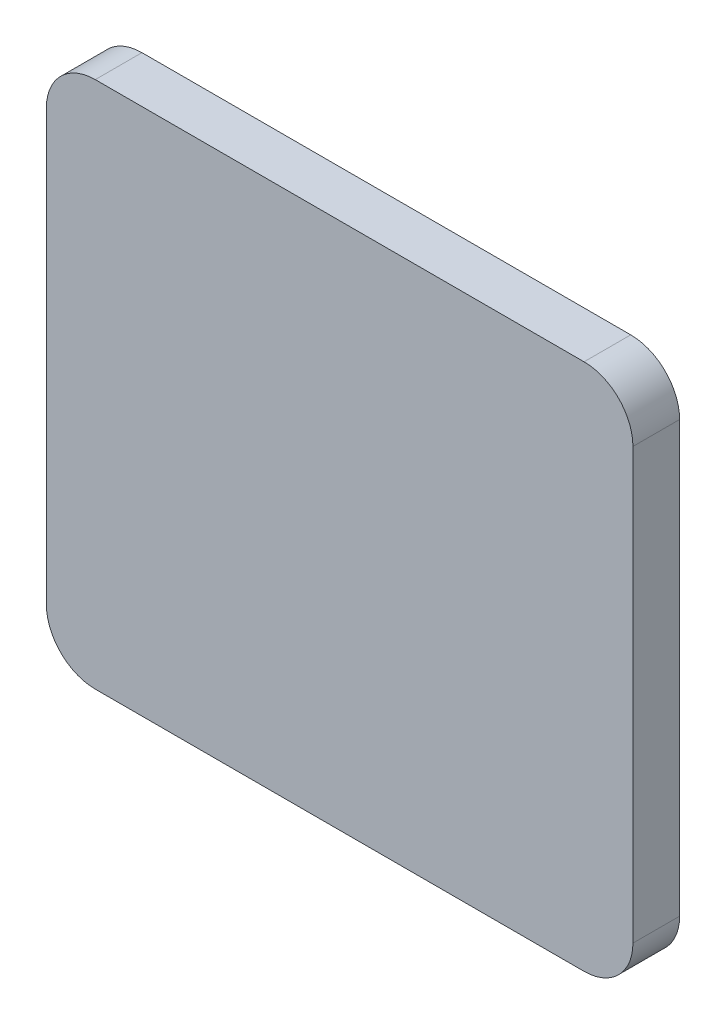
from build123d import *

# Parameters (mm, degrees)
BOSS_EXTRUDE1_DEPTH = 4.7752


with BuildPart() as part:
    # Sketch1 → Boss-Extrude1 (new body)
    with BuildSketch(Plane.XY):
        with BuildLine():
            Line((0, 5), (0, 49))
            ThreePointArc((0, 49), (1.464466094, 52.535533906), (5, 54))
            Line((5, 54), (55, 54))
            ThreePointArc((55, 54), (58.535533906, 52.535533906), (60, 49))
            Line((60, 49), (60, 5))
            ThreePointArc((60, 5), (58.535533906, 1.464466094), (55, 0))
            Line((55, 0), (5, 0))
            ThreePointArc((5, 0), (1.464466094, 1.464466094), (0, 5))
        make_face()
    extrude(amount=BOSS_EXTRUDE1_DEPTH)


solid = part.part
